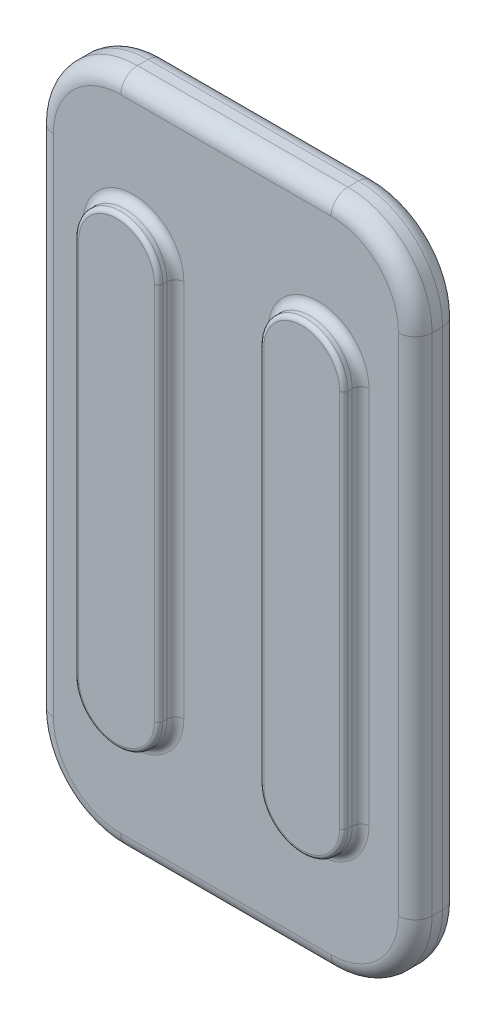
from build123d import *

# Parameters (mm, degrees)
SKETCH_1_W      = 450
SKETCH_1_H      = 800
EXTRUDE_1_DEPTH = 52.484908593
EXTRUDE_2_DEPTH = 20
FILLET_1_R      = 100
FILLET_2_R      = 10
FILLET_3_R      = 5
FILLET_4_R      = 20
EXTRUDE_START   = -100
EXTRUDE_3_DEPTH = 670


with BuildPart() as part:
    # 草图1 → 凸台-拉伸1 (new body)
    with BuildSketch(Plane.XY):
        Rectangle(SKETCH_1_W, SKETCH_1_H)
    extrude(amount=EXTRUDE_1_DEPTH)

    # 草图2 → 凸台-拉伸2 (add)
    with BuildSketch(Plane.XY.offset(52.484908593)):
        with BuildLine():
            Line((-60, 225), (-60, -225))
            ThreePointArc((-60, -225), (-110, -275), (-160, -225))
            Line((-160, -225), (-160, 225))
            ThreePointArc((-160, 225), (-110, 275), (-60, 225))
        make_face()
        with BuildLine():
            Line((60, 225), (60, -225))
            ThreePointArc((60, -225), (110, -275), (160, -225))
            Line((160, -225), (160, 225))
            ThreePointArc((160, 225), (110, 275), (60, 225))
        make_face()
    extrude(amount=EXTRUDE_2_DEPTH)

    # 圆角1
    fillet_1_edges = [part.edges().sort_by_distance(p)[0] for p in [
        (225, -400, 26.242454296),
        (-225, -400, 26.242454296),
        (-225, 400, 26.242454296),
        (225, 400, 26.242454296),
    ]]
    fillet(fillet_1_edges, radius=FILLET_1_R)

    # 圆角2
    fillet_2_edges = [part.edges().sort_by_distance(p)[0] for p in [
        (-110, 275, 52.484908593),
        (-160, 0, 52.484908593),
        (-110, -275, 52.484908593),
        (-60, 0, 52.484908593),
        (110, 275, 52.484908593),
        (60, 0, 52.484908593),
        (110, -275, 52.484908593),
        (160, 0, 52.484908593),
    ]]
    fillet(fillet_2_edges, radius=FILLET_2_R)

    # 圆角3
    fillet_3_edges = [part.edges().sort_by_distance(p)[0] for p in [
        (-110, 275, 72.484908593),
        (-160, 0, 72.484908593),
        (-110, -275, 72.484908593),
        (-60, 0, 72.484908593),
        (110, 275, 72.484908593),
        (60, 0, 72.484908593),
        (110, -275, 72.484908593),
        (160, 0, 72.484908593),
    ]]
    fillet(fillet_3_edges, radius=FILLET_3_R)

    # 圆角4
    fillet_4_edges = [part.edges().sort_by_distance(p)[0] for p in [
        (0, 400, 0),
        (0, 400, 52.484908593),
        (225, 0, 0),
        (0, -400, 0),
        (-225, 0, 0),
        (-195.710678119, -370.710678119, 0),
        (195.710678119, -370.710678119, 0),
        (-195.710678119, 370.710678119, 0),
        (195.710678119, 370.710678119, 0),
        (225, 0, 52.484908593),
        (-225, 0, 52.484908593),
        (0, -400, 52.484908593),
        (-195.710678119, -370.710678119, 52.484908593),
        (195.710678119, -370.710678119, 52.484908593),
        (-195.710678119, 370.710678119, 52.484908593),
        (195.710678119, 370.710678119, 52.484908593),
    ]]
    fillet(fillet_4_edges, radius=FILLET_4_R)

    # 草图3 → 凸台-拉伸3 (add)
    with BuildSketch(Plane(origin=(0, 400, 0), x_dir=(1, 0, 0), z_dir=(0, 1, 0)).offset(EXTRUDE_START)):
        Polygon((-159.75, 0), (-110.25, 0), (-110.25, 7.38), (-122.225, 19.39), (-147.775, 19.39), (-159.75, 7.38), align=None)
        Polygon((159.75, 0), (159.75, 7.38), (147.775, 19.39), (122.225, 19.39), (110.25, 7.38), (110.25, 0), align=None)
    extrude(amount=-EXTRUDE_3_DEPTH)


solid = part.part
